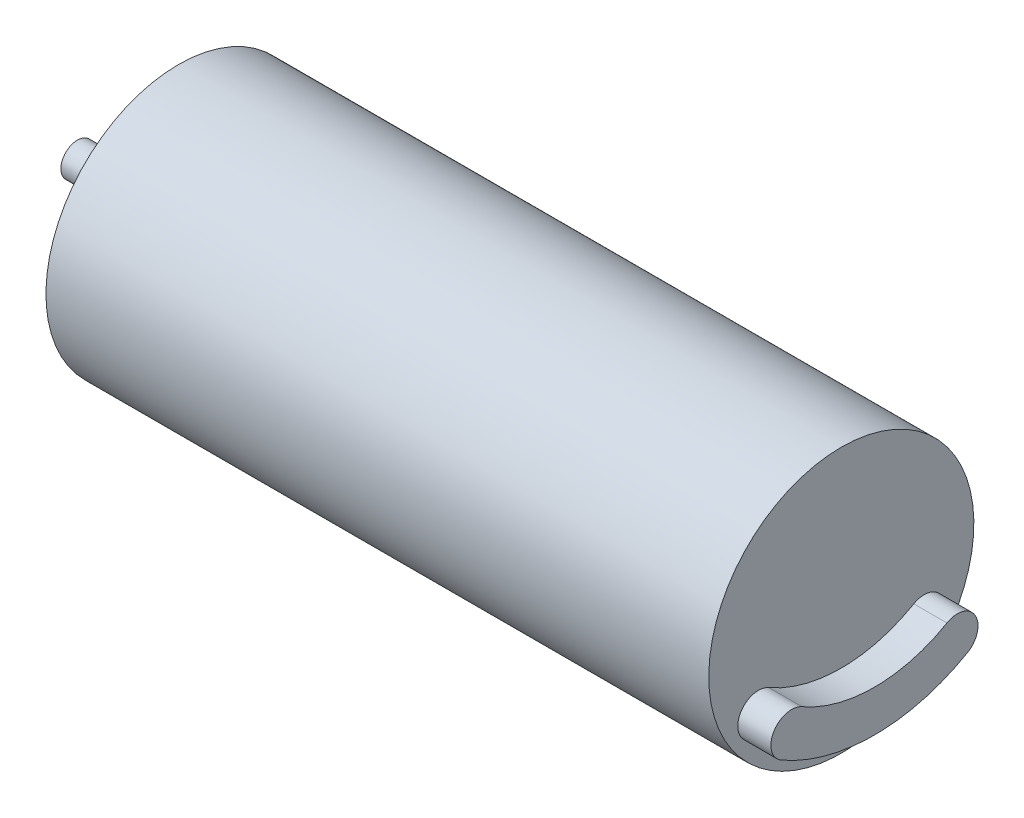
from build123d import *

# Parameters (mm, degrees)
SKETCH9_W           = 5.1
SKETCH9_H           = 1
SKETCH11_W          = 40
SKETCH11_H          = 8
BOSS_EXTRUDE3_DEPTH = 2
SKETCH20_R          = 4.5
BOSS_EXTRUDE4_DEPTH = 1
SKETCH21_W          = 3.5
SKETCH21_H          = 0.5
SKETCH23_W          = 0.7835
SKETCH23_H          = 3.5
HOLE2_AT_2_COUNT    = 2
HOLE2_AT_2_PITCH    = 9.526279442
HOLE2_AT_3_COUNT    = 2
HOLE2_AT_3_PITCH    = 9.526279442


with BuildPart() as part:
    # Sketch9 → Revolve2 (revolve)
    with BuildSketch(Plane.XY):
        with Locations((-20.5, 0.5)):
            Rectangle(SKETCH9_W, SKETCH9_H)
    revolve(axis=Axis((-23.05, 0, 0), (1, 0, 0)))

    # Sketch21 → Ø7.0 (7) Diameter Hole2 (revolve, cut)
    with BuildSketch(Plane(origin=(-17.95, 0, 0), x_dir=(0, 0, -1), z_dir=(0, 1, 0))):
        with Locations((1.75, 0.25)):
            Rectangle(SKETCH21_W, SKETCH21_H)
    revolve(axis=Axis((-11.6, 0, 0), (-1, 0, 0)), mode=Mode.SUBTRACT)


with BuildPart() as body_2:
    # Sketch11 → Revolve3 (revolve)
    with BuildSketch(Plane.XY):
        with Locations((3.05, 4)):
            Rectangle(SKETCH11_W, SKETCH11_H)
    revolve(axis=Axis((-16.95, 0, 0), (1, 0, 0)))

    # Sketch23 → Hole2 (revolve, cut)
    with BuildSketch(Plane(origin=(-16.95, -2.75, -4.763139721), x_dir=(0, 0, 1), z_dir=(0, 1, 0))):
        with Locations((0.39175, 1.75)):
            Rectangle(SKETCH23_W, SKETCH23_H)
    hole2 = revolve(axis=Axis((93.05, -2.75, -4.763139721), (-1, 0, 0)), mode=Mode.SUBTRACT)

    # Hole2 at 2: Hole2 ×2
    with Locations(*[(0, 0, i * HOLE2_AT_2_PITCH) for i in range(1, HOLE2_AT_2_COUNT)]):
        add(hole2, mode=Mode.SUBTRACT)

    # Hole2 at 3: Hole2 ×2
    with Locations(*[Vector(0, 0.866025404, 0.5) * (i * HOLE2_AT_3_PITCH) for i in range(1, HOLE2_AT_3_COUNT)]):
        add(hole2, mode=Mode.SUBTRACT)


with BuildPart() as body_3:
    # Sketch15 → Boss-Extrude3 (new body)
    with BuildSketch(Plane(origin=(23.05, 0, 0), x_dir=(0, 0, -1), z_dir=(1, 0, 0))):
        with BuildLine():
            ThreePointArc((4.375, -2.377722283), (6.082531755, -2.835254038), (5.625, -4.542785793))
            ThreePointArc((5.625, -4.542785793), (0, -6.05), (-5.625, -4.542785793))
            ThreePointArc((-5.625, -4.542785793), (-6.082531755, -2.835254038), (-4.375, -2.377722283))
            ThreePointArc((-4.375, -2.377722283), (0, -3.55), (4.375, -2.377722283))
        make_face()
    extrude(amount=BOSS_EXTRUDE3_DEPTH)


with BuildPart() as body_4:
    # Sketch20 → Boss-Extrude4 (new body)
    with BuildSketch(Plane.ZY.offset(16.95)):
        Circle(SKETCH20_R)
    extrude(amount=BOSS_EXTRUDE4_DEPTH)


solid = Compound([part.part, body_2.part, body_3.part, body_4.part])
